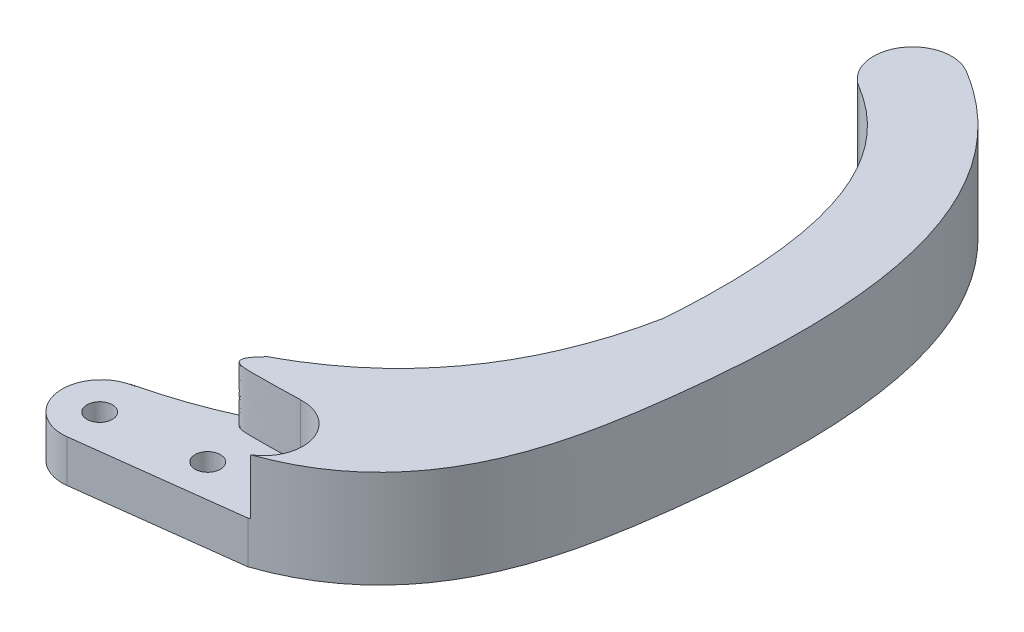
from build123d import *

# Parameters (mm, degrees)
EXTRUDE_1_DEPTH     = 5
CUT_EXTRUDE_3_DEPTH = 36.932997264
SKETCH_6_R          = 0.65
CUT_EXTRUDE_4_DEPTH = 37.508731303
SKETCH_7_R          = 1.25
CUT_EXTRUDE_5_DEPTH = 0.85
EXTRUDE_2_DEPTH     = 2.837273549
EXTRUDE_3_DEPTH     = 2.162726451
EXTRUDE_4_DEPTH     = 2.837273549


with BuildPart() as part:
    # 草图1 → 凸台-拉伸1 (new body)
    with BuildSketch(Plane(origin=(0, 0, 0), x_dir=(1, 0, 0), z_dir=(0, 1, 0))):
        with BuildLine():
            Line((-11.532787565, -27.66331715), (-19.756338957, -28.685777545))
            ThreePointArc((-19.756338957, -28.685777545), (-21.987823516, -26.947825687), (-20.249871658, -24.716341127))
            Line((-20.249871658, -24.716341127), (-12.48156417, -23.75048266))
            add(Edge.make_bspline(
                [(-12.48156417, -23.75048266), (-12.295612378, -23.67796581), (-11.920949946, -23.514760542), (-11.264517505, -23.162027697), (-10.551390656, -22.655406839), (-9.837584569, -21.94614323), (-9.026907466, -20.848225864), (-8.238987931, -19.16416179), (-7.602196611, -16.706089731), (-7.189047715, -13.934273469), (-6.893621745, -11.087804415), (-6.772952472, -8.470611277), (-6.854171877, -5.379387305), (-7.367845034, -2.192874406), (-8.514649439, 0.65647794), (-9.829040758, 2.401950035), (-11.094940182, 3.531874214), (-11.819819389, 4.028598999), (-12.191592735, 4.253212063)],
                knots=[0.005238239, 0.005238239, 0.005238239, 0.005238239, 0.020781392, 0.036324544, 0.067410849, 0.098497154, 0.129583459, 0.191756069, 0.253928679, 0.316101289, 0.3782739, 0.44044651, 0.50261912, 0.62696434, 0.75130956, 0.87565478, 0.93782739, 1, 1, 1, 1], degree=3))
            ThreePointArc((-12.191592735, 4.253212063), (-12.869192539, 6.999274426), (-10.123130176, 7.67687423))
            add(Edge.make_bspline(
                [(-11.532787565, -27.66331715), (-11.470532884, -27.640873613), (-11.355102626, -27.59953383), (-11.051609278, -27.488475951), (-10.551343717, -27.286553928), (-9.584901148, -26.829408766), (-7.854575968, -25.725812711), (-5.96542891, -23.675110376), (-4.556446234, -20.819990637), (-3.731942919, -17.796654668), (-3.257587757, -14.742999785), (-2.927918963, -11.698935156), (-2.772480823, -8.76409887), (-2.841981487, -5.204938932), (-3.425083428, -1.318171114), (-4.918570201, 2.52848265), (-7.182233346, 5.575301279), (-9.090959394, 7.05327105), (-10.123130176, 7.67687423)],
                knots=[-0.004411621, -0.004411621, -0.004411621, -0.004411621, -0.000488138, 0.003435345, 0.011282311, 0.026976242, 0.058364105, 0.121139832, 0.183915558, 0.246691284, 0.309467011, 0.372242737, 0.435018463, 0.49779419, 0.623345642, 0.748897095, 0.874448547, 1, 1, 1, 1], degree=3))
        make_face()
    extrude(amount=EXTRUDE_1_DEPTH)

    # 草图5 → 切除-拉伸3 (cut, through all)
    with BuildSketch(Plane.XY.offset(20)):
        Polygon((-22.003105308, 4.162726451), (-22.003105308, 5), (-10.276836703, 5), (-10.276836703, 4.162726451), (-10.276836703, 2.162726451), (-22.003105308, 2.162726451), align=None)
    extrude(amount=CUT_EXTRUDE_3_DEPTH, mode=Mode.SUBTRACT)

    # 草图6 → 切除-拉伸4 (cut, through all)
    with BuildSketch(Plane(origin=(0, 5, 0), x_dir=(1, 0, 0), z_dir=(0, 1, 0))):
        with Locations(Location((-20.021110813, -26.759262863, 0), (0, 0, 270))):
            Circle(SKETCH_6_R)
        with Locations(Location((-15.048958849, -26.204756434, 0), (0, 0, 270))):
            Circle(SKETCH_6_R)
    extrude(amount=-CUT_EXTRUDE_4_DEPTH, mode=Mode.SUBTRACT)

    # 草图7 → 切除-拉伸5 (cut)
    with BuildSketch(Plane.XZ):
        with Locations(Location((-20.021110813, 26.759262863, 0), (0, 0, 270))):
            Circle(SKETCH_7_R)
        with Locations(Location((-15.048958849, 26.204756434, 0), (0, 0, 270))):
            Circle(SKETCH_7_R)
    extrude(amount=-CUT_EXTRUDE_5_DEPTH, mode=Mode.SUBTRACT)

    # 草图8 → 凸台-拉伸2 (add)
    with BuildSketch(Plane(origin=(0, 2.162726451, 0), x_dir=(1, 0, 0), z_dir=(0, 1, 0))):
        with BuildLine():
            Line((-12.48156417, -23.75048266), (-12.580826815, -23.920103142))
            ThreePointArc((-12.580826815, -23.920103142), (-10.558019351, -25.323434722), (-11.429255903, -27.626049851))
            add(Edge.make_bspline(
                [(-11.429255903, -27.626049851), (-11.402483913, -27.616408571), (-11.312274879, -27.583861794), (-11.051609278, -27.488475951), (-10.694139024, -27.344190351), (-10.414634593, -27.218588376), (-10.276836703, -27.153356774)],
                knots=[-0.002196957, -0.002196957, -0.002196957, -0.002196957, -0.000488138, 0.003435345, 0.011282311, 0.019136837, 0.019136837, 0.019136837, 0.019136837], degree=3))
            Line((-10.276836703, -27.153356774), (-10.276836703, -22.371362309))
            add(Edge.make_bspline(
                [(-10.276836703, -22.371362309), (-10.372821557, -22.463117226), (-10.724386033, -22.778306526), (-11.264517505, -23.162027697), (-11.920949946, -23.514760542), (-12.295612378, -23.67796581), (-12.48156417, -23.75048266)],
                knots=[0.925593927, 0.925593927, 0.925593927, 0.925593927, 0.93782739, 0.968913695, 0.984456847, 1, 1, 1, 1], degree=3))
        make_face()
    extrude(amount=EXTRUDE_2_DEPTH)

    # 草图9 → 凸台-拉伸3 (add)
    with BuildSketch(Plane.XZ):
        with BuildLine():
            Line((-20.489918003, 24.746186856), (-12.48156417, 23.75048266))
            add(Edge.make_bspline(
                [(-12.48156417, 23.75048266), (-12.295612378, 23.67796581), (-11.920949946, 23.514760542), (-11.264517505, 23.162027697), (-10.551390656, 22.655406839), (-9.837584569, 21.94614323), (-9.026907466, 20.848225864), (-8.238987931, 19.16416179), (-7.602196611, 16.706089731), (-7.189047715, 13.934273469), (-6.987988897, 11.997044646), (-6.917012362, 11.050106293), (-6.91422073, 11.012251503)],
                knots=[0.005238239, 0.005238239, 0.005238239, 0.005238239, 0.020781392, 0.036324544, 0.067410849, 0.098497154, 0.129583459, 0.191756069, 0.253928679, 0.316101289, 0.3782739, 0.380867603, 0.380867603, 0.380867603, 0.380867603], degree=3))
            add(Edge.make_bspline(
                [(-20.489918003, 24.746186856), (-9.085568026, 22.00342521), (-6.91422073, 11.012251503)],
                knots=[0, 0, 0, 1, 1, 1], degree=2))
        make_face()
    extrude(amount=-EXTRUDE_3_DEPTH)

    # 草图10 → 凸台-拉伸4 (add)
    with BuildSketch(Plane(origin=(0, 2.162726451, 0), x_dir=(1, 0, 0), z_dir=(0, 1, 0))):
        with BuildLine():
            Line((-12.48156417, -23.75048266), (-12.573747328, -23.90800568))
            add(Edge.make_bspline(
                [(-12.573747328, -23.90800568), (-13.049488997, -23.93391524), (-14.700965999, -23.963867562), (-16.426938548, -23.94912182), (-15.35263855, -22.852847317)],
                knots=[0, 0, 0, 0, 0.570111163, 1, 1, 1, 1], degree=3))
            add(Edge.make_bspline(
                [(-15.35263855, -22.852847317), (-8.541278489, -19.248278275), (-6.91422073, -11.012251503)],
                knots=[0, 0, 0, 1, 1, 1], degree=2))
            add(Edge.make_bspline(
                [(-6.91422073, -11.012251503), (-6.917012362, -11.050106293), (-6.987988897, -11.997044646), (-7.189047715, -13.934273469), (-7.602196611, -16.706089731), (-8.238987931, -19.16416179), (-9.026907466, -20.848225864), (-9.837584569, -21.94614323), (-10.551390656, -22.655406839), (-11.264517505, -23.162027697), (-11.920949946, -23.514760542), (-12.295612378, -23.67796581), (-12.48156417, -23.75048266)],
                knots=[0.624370637, 0.624370637, 0.624370637, 0.624370637, 0.62696434, 0.68913695, 0.75130956, 0.81348217, 0.87565478, 0.906741085, 0.93782739, 0.968913695, 0.984456847, 1, 1, 1, 1], degree=3))
        make_face()
    extrude(amount=EXTRUDE_4_DEPTH)


solid = part.part
